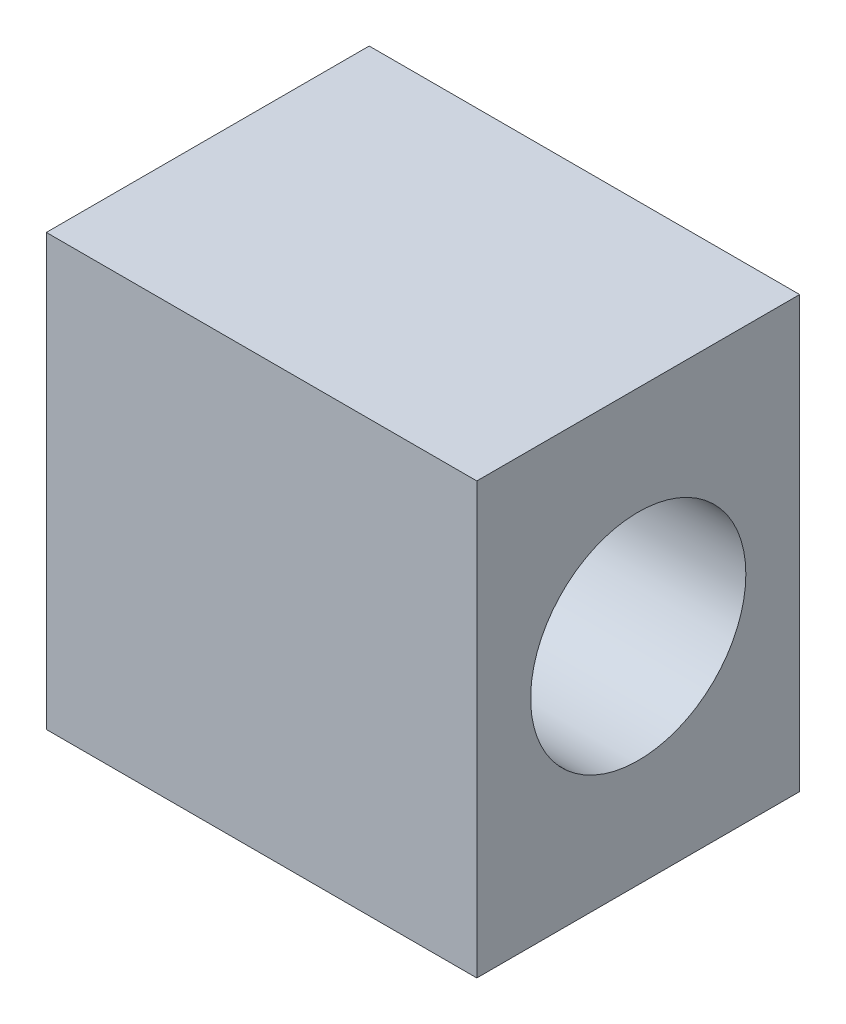
from build123d import *

# Parameters (mm, degrees)
SKETCH3_W           = 20
SKETCH3_H           = 15
BOSS_EXTRUDE1_DEPTH = 20
SKETCH5_R           = 5
CUT_EXTRUDE1_DEPTH  = 10
SKETCH7_R           = 5
CUT_EXTRUDE6_DEPTH  = 4


with BuildPart() as part:
    # Sketch3 → Boss-Extrude1 (new body)
    with BuildSketch(Plane(origin=(0, 0, 0), x_dir=(1, 0, 0), z_dir=(0, 1, 0))):
        Rectangle(SKETCH3_W, SKETCH3_H)
    extrude(amount=BOSS_EXTRUDE1_DEPTH)

    # Sketch5 → Cut-Extrude1 (cut)
    with BuildSketch(Plane(origin=(10, 0, 0), x_dir=(0, 0, -1), z_dir=(1, 0, 0))):
        with Locations((0, 10)):
            Circle(SKETCH5_R)
    extrude(amount=-CUT_EXTRUDE1_DEPTH, mode=Mode.SUBTRACT)

    # Sketch7 → Cut-Extrude6 (cut)
    with BuildSketch(Plane.XZ):
        Circle(SKETCH7_R)
    extrude(amount=-CUT_EXTRUDE6_DEPTH, mode=Mode.SUBTRACT)


solid = part.part
